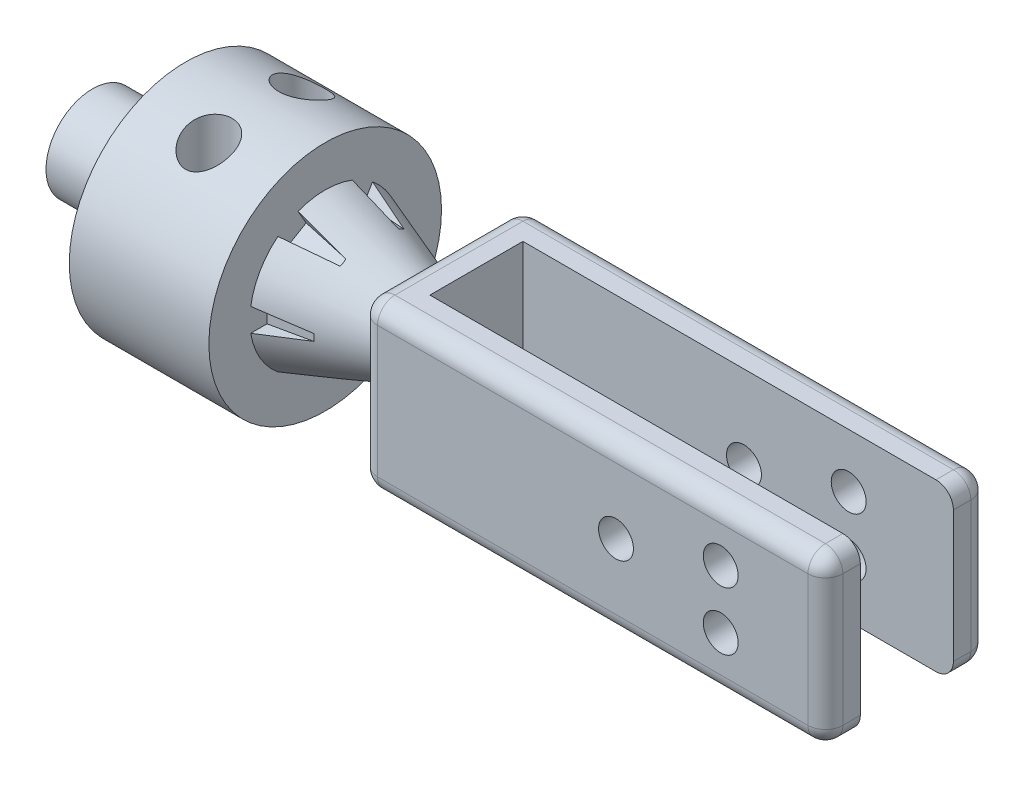
from build123d import *

# Parameters (mm, degrees)
SKETCH2_R               = 90
CUT_EXTRUDE1_DEPTH      = 10
SKETCH3_W               = 140
SKETCH3_H               = 142.82856857
BOSS_EXTRUDE1_DEPTH     = 400
FILLET1_R               = 15
CUT_EXTRUDE4_START      = 50
SKETCH6_R               = 20
CUT_EXTRUDE4_DEPTH      = 54
CUT_EXTRUDE5_START      = 50
CUT_EXTRUDE5_DEPTH      = 54
CIRPATTERN1_COUNT       = 6
SKETCH8_W               = 340
SKETCH8_H               = 80
CUT_EXTRUDE6_DEPTH      = 172.414284385
SKETCH9_R               = 15
CUT_EXTRUDE7_DEPTH      = 171.0000001
SKETCH10_W              = 30
SKETCH10_H              = 80
CUT_EXTRUDE8_DEPTH      = 101.0000001
CUT_EXTRUDE8_DEPTH_BACK = 101.0000001


with BuildPart() as part:
    # Sketch1 → Revolve1 (revolve)
    with BuildSketch(Plane.XY):
        Polygon((0, 0), (0, 40), (80, 40), (80, 100), (200, 100), (200, 64.750957854), (300, 28.353934428), (300, 0), align=None)
    revolve(axis=Axis((-5657.507821664, 0, 0), (1, 0, 0)))

    # Sketch2 → Cut-Extrude1 (cut)
    with BuildSketch(Plane.ZY.offset(-80)):
        Circle(SKETCH2_R)
    extrude(amount=-CUT_EXTRUDE1_DEPTH, mode=Mode.SUBTRACT)

    # Sketch3 → Boss-Extrude1 (add)
    with BuildSketch(Plane(origin=(300, 0, 0), x_dir=(0, 0, -1), z_dir=(1, 0, 0))):
        Rectangle(SKETCH3_W, SKETCH3_H)
    extrude(amount=BOSS_EXTRUDE1_DEPTH)

    # Fillet1
    fillet1_edges = [part.edges().sort_by_distance(p)[0] for p in [
        (700, -71.414284285, 0),
        (700, 0, -70),
        (700, 71.414284285, 0),
        (300, -28.353934428, 0),
        (300, 0, 70),
        (500, 71.414284285, 70),
        (300, -71.414284285, 0),
        (500, -71.414284285, 70),
        (300, 0, -70),
        (500, -71.414284285, -70),
        (300, 71.414284285, 0),
        (500, 71.414284285, -70),
        (700, 0, 70),
    ]]
    fillet(fillet1_edges, radius=FILLET1_R)

    # Sketch6 → Cut-Extrude4 (cut)
    with BuildSketch(Plane(origin=(0, 0, 0), x_dir=(1, 0, 0), z_dir=(0, 1, 0)).offset(CUT_EXTRUDE4_START)):
        with Locations((140, 40)):
            Circle(SKETCH6_R)
        with Locations((140, -40)):
            Circle(SKETCH6_R)
    extrude(amount=CUT_EXTRUDE4_DEPTH, mode=Mode.SUBTRACT)

    # Sketch7 → Cut-Extrude5 (cut)
    with BuildSketch(Plane.XY.offset(CUT_EXTRUDE5_START)):
        with BuildLine():
            Line((200, 10), (242.534613647, 2.5))
            ThreePointArc((242.534613647, 2.5), (243.876301252, 0), (242.534613647, -2.5))
            Line((242.534613647, -2.5), (200, -10))
            Line((200, -10), (200, 10))
        make_face()
    cut_extrude5 = extrude(amount=CUT_EXTRUDE5_DEPTH, mode=Mode.SUBTRACT)

    # CirPattern1: Cut-Extrude5 ×6 about axis
    cirpattern1_axis = Axis((0, 0, 0), (1, 0, 0))
    for i in range(1, CIRPATTERN1_COUNT):
        add(cut_extrude5.rotate(cirpattern1_axis, i * 360 / CIRPATTERN1_COUNT), mode=Mode.SUBTRACT)

    # Sketch8 → Cut-Extrude6 (cut, through all)
    with BuildSketch(Plane(origin=(0, 71.414284285, 0), x_dir=(1, 0, 0), z_dir=(0, 1, 0))):
        with Locations((500, 0)):
            Rectangle(SKETCH8_W, SKETCH8_H)
    extrude(amount=-CUT_EXTRUDE6_DEPTH, mode=Mode.SUBTRACT)

    # Sketch9 → Cut-Extrude7 (cut, through all)
    with BuildSketch(Plane.XY.offset(70)):
        with Locations((520, 0)):
            Circle(SKETCH9_R)
        with Locations((610, 25)):
            Circle(SKETCH9_R)
        with Locations((610, -25)):
            Circle(SKETCH9_R)
    extrude(amount=-CUT_EXTRUDE7_DEPTH, mode=Mode.SUBTRACT)

    # Sketch10 → Cut-Extrude8 (cut, two sides)
    with BuildSketch(Plane(origin=(0, 0, 0), x_dir=(1, 0, 0), z_dir=(0, 1, 0))) as cut_extrude8_sk:
        with Locations((685, 0)):
            Rectangle(SKETCH10_W, SKETCH10_H)
    extrude(amount=CUT_EXTRUDE8_DEPTH, mode=Mode.SUBTRACT)
    extrude(cut_extrude8_sk.sketch, amount=-CUT_EXTRUDE8_DEPTH_BACK, mode=Mode.SUBTRACT)


solid = part.part
